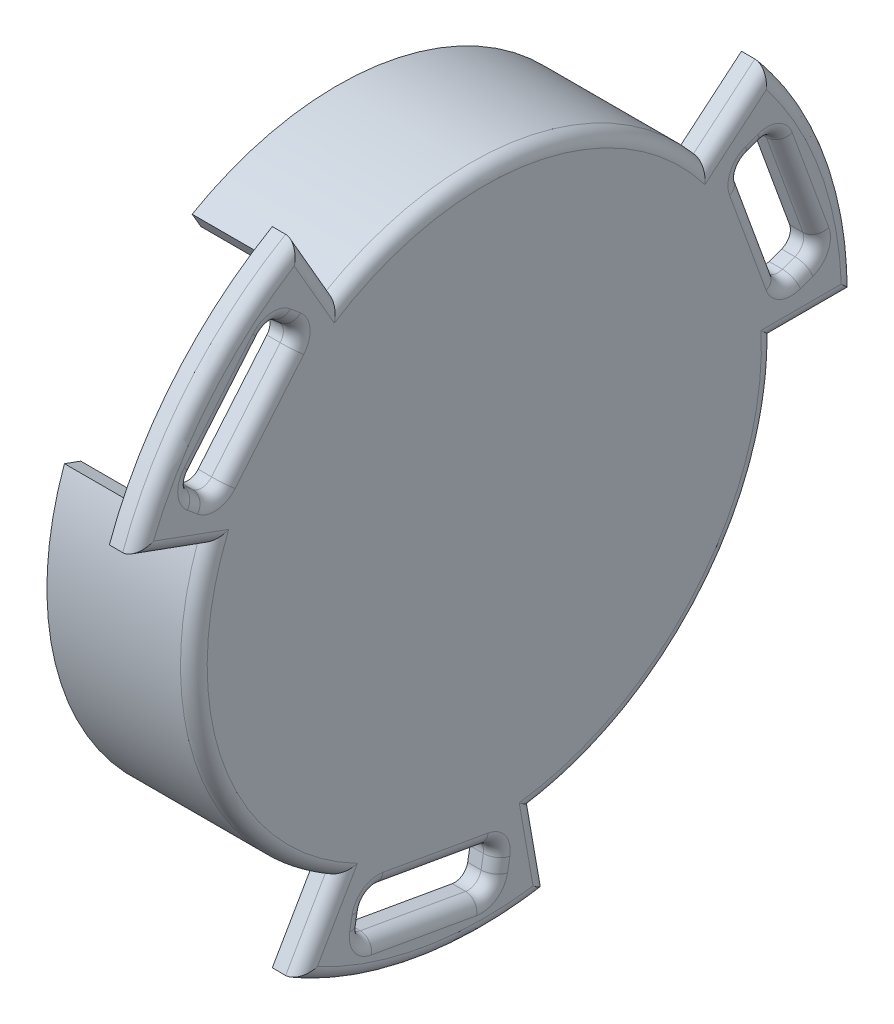
from build123d import *

# Parameters (mm, degrees)
SKETCH1_R                = 21.75
BOSS_EXTRUDE1_DEPTH      = 1
SKETCH2_R                = 18
BOSS_EXTRUDE2_DEPTH      = 1.5
BOSS_EXTRUDE2_TAPER      = 40
SKETCH3_R                = 21.75
SKETCH3_R_2              = 20.45
BOSS_EXTRUDE3_DEPTH      = 10
CUT_REVOLVE1_ANGLE       = 40
CIRPATTERN1_COUNT        = 3
SKETCH8_W                = 2
SKETCH8_H                = 6
REVOLVE1_ANGLE           = 40
CUT_EXTRUDE1_DEPTH       = 10
FILLET5_R                = 1
CIRPATTERN3_COUNT        = 3
FILLET5_OF_CIRPATTERN3_R = 1
FILLET6_R                = 1


with BuildPart() as part:
    # Sketch1 → Boss-Extrude1 (new body)
    with BuildSketch(Plane(origin=(0, 0, 0), x_dir=(0, 0, -1), z_dir=(1, 0, 0))):
        Circle(SKETCH1_R)
    extrude(amount=BOSS_EXTRUDE1_DEPTH)

    # Sketch2 → Boss-Extrude2 (add)
    with BuildSketch(Plane.ZY):
        Circle(SKETCH2_R)
    extrude(amount=BOSS_EXTRUDE2_DEPTH, taper=BOSS_EXTRUDE2_TAPER)

    # Sketch3 → Boss-Extrude3 (add)
    with BuildSketch(Plane.ZY):
        Circle(SKETCH3_R)
        Circle(SKETCH3_R_2, mode=Mode.SUBTRACT)
    extrude(amount=BOSS_EXTRUDE3_DEPTH)

    # Sketch6 → Cut-Revolve1 (revolve, cut)
    with BuildSketch(Plane(origin=(0, 0, 0), x_dir=(1, 0, 0), z_dir=(0, 1, 0))):
        Polygon((-10, 21.75), (-10, 19.75), (-1, 18.5), (-1, 21.75), align=None)
    cut_revolve1 = revolve(axis=Axis((-10, 0, 0), (1, 0, 0)), revolution_arc=CUT_REVOLVE1_ANGLE, mode=Mode.SUBTRACT)

    # CirPattern1: Cut-Revolve1 ×3 about axis
    cirpattern1_axis = Axis((0, 0, 0), (1, 0, 0))
    for i in range(1, CIRPATTERN1_COUNT):
        add(cut_revolve1.rotate(cirpattern1_axis, i * 360 / CIRPATTERN1_COUNT), mode=Mode.SUBTRACT)

    # Sketch8 → Revolve1 (revolve)
    with BuildSketch(Plane(origin=(0, 0, 0), x_dir=(1, 0, 0), z_dir=(0, 1, 0))):
        with Locations((0, 24.75)):
            Rectangle(SKETCH8_W, SKETCH8_H)
    revolve1 = revolve(axis=Axis((-10, 0, 0), (1, 0, 0)), revolution_arc=REVOLVE1_ANGLE)

    # Sketch9 → Cut-Extrude1 (cut)
    with BuildSketch(Plane.ZY.offset(1)):
        Polygon((-20.673237657, 7.524443153), (-22.383338374, 2.825980049), (-25.202416236, 3.852040479), (-21.782214803, 13.248966687), (-18.963136941, 12.222906257), align=None)
    cut_extrude1 = extrude(amount=-CUT_EXTRUDE1_DEPTH, mode=Mode.SUBTRACT)

    # Fillet5
    fillet5_edges = [part.edges().sort_by_distance(p)[0] for p in [
        (0, 12.222906257, -18.963136941),
        (0, 2.825980049, -22.383338374),
        (0, 3.852040479, -25.202416236),
        (0, 13.248966687, -21.782214803),
    ]]
    fillet(fillet5_edges, radius=FILLET5_R)

    # CirPattern3: Revolve1, Cut-Extrude1 ×3 about axis
    cirpattern3_axis = Axis((0, 0, 0), (1, 0, 0))
    for i in range(1, CIRPATTERN3_COUNT):
        add(revolve1.rotate(cirpattern3_axis, i * 360 / CIRPATTERN3_COUNT))
        add(cut_extrude1.rotate(cirpattern3_axis, i * 360 / CIRPATTERN3_COUNT), mode=Mode.SUBTRACT)

    # Fillet5 of CirPattern3
    fillet5_of_cirpattern3_edges = [part.edges().sort_by_distance(p)[0] for p in [
        (0, 10.311105198, 20.066915797),
        (0, 17.971549629, 13.6390397),
        (0, 19.899912458, 15.93717303),
        (0, 12.239468027, 22.365049126),
        (0, -22.534011455, -1.103778856),
        (0, -20.797529678, 8.744298674),
        (0, -23.751952937, 9.265243207),
        (0, -25.488434714, -0.582834323),
    ]]
    fillet(fillet5_of_cirpattern3_edges, radius=FILLET5_OF_CIRPATTERN3_R)

    # Fillet6
    fillet6_edges = [part.edges().sort_by_distance(p)[0] for p in [
        (1, 4.027094695, -24.827011259),
        (1, 3.201385026, -22.55839259),
        (1, 12.047852041, -19.338541918),
        (1, 12.87356171, -21.607160587),
        (1, -7.438938117, 20.438314502),
        (1, 17.837356169, 21.257733297),
        (1, 21.434128744, 12.375),
        (1, 8.464998547, 23.257392364),
        (1, -13.980630511, -16.661466638),
        (1, -27.328415146, 4.81873693),
        (1, -21.434128744, 12.375),
        (1, -24.373991887, -4.297792397),
        (1, 18.935731043, 14.788106365),
        (1, 16.069690242, 19.151111078),
        (1, 14.141327413, 16.852977749),
        (1, 11.275286612, 21.215982462),
        (1, 19.487275103, 15.901071939),
        (1, 17.935448538, 14.051677055),
        (1, 10.723742552, 20.103016888),
        (1, 12.275569117, 21.952411772),
        (1, -22.274741307, 9.00477094),
        (1, -24.620193825, 4.341204442),
        (1, -21.665770566, 3.820259909),
        (1, -24.011223084, -0.84330659),
        (1, -23.514369798, 8.92593932),
        (1, -21.136833564, 8.506715535),
        (1, -22.771594594, -0.76447497),
        (1, -25.149130827, -0.345251184),
        (1, 21.419568628, -3.776847864),
        (1, 9.491058977, -26.076470227),
        (1, 0, -24.75),
        (1, 15.90899334, -18.959599967),
        (1, 3.339010264, -23.792877305),
        (1, 8.550503583, -23.49231552),
        (1, 7.524443153, -20.673237657),
        (1, 12.735936472, -20.372675872),
    ]]
    fillet(fillet6_edges, radius=FILLET6_R)


solid = part.part
